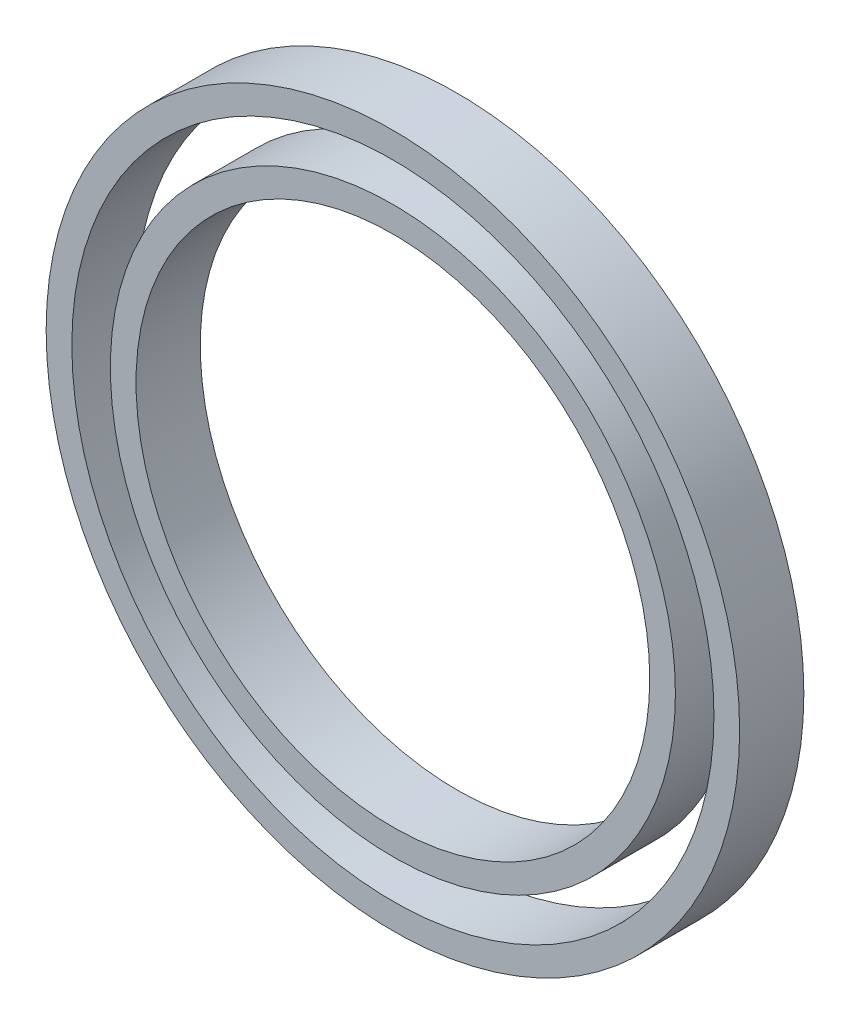
from build123d import *

# Parameters (mm, degrees)
SKETCH1_R             = 22
SKETCH1_R_2           = 20
BOSS_EXTRUDE3_DEPTH   = 5
SKETCH1_R_3           = 27
SKETCH1_R_4           = 25
BOSS_EXTRUDE3_2_DEPTH = 5


with BuildPart() as part:
    # Sketch1 → Boss-Extrude3 (new body)
    with BuildSketch(Plane.XY):
        Circle(SKETCH1_R)
        Circle(SKETCH1_R_2, mode=Mode.SUBTRACT)
    extrude(amount=BOSS_EXTRUDE3_DEPTH)


with BuildPart() as body_2:
    # Sketch1 → Boss-Extrude3 2 (new body)
    with BuildSketch(Plane.XY):
        Circle(SKETCH1_R_3)
        Circle(SKETCH1_R_4, mode=Mode.SUBTRACT)
    extrude(amount=BOSS_EXTRUDE3_2_DEPTH)


solid = Compound([part.part, body_2.part])
